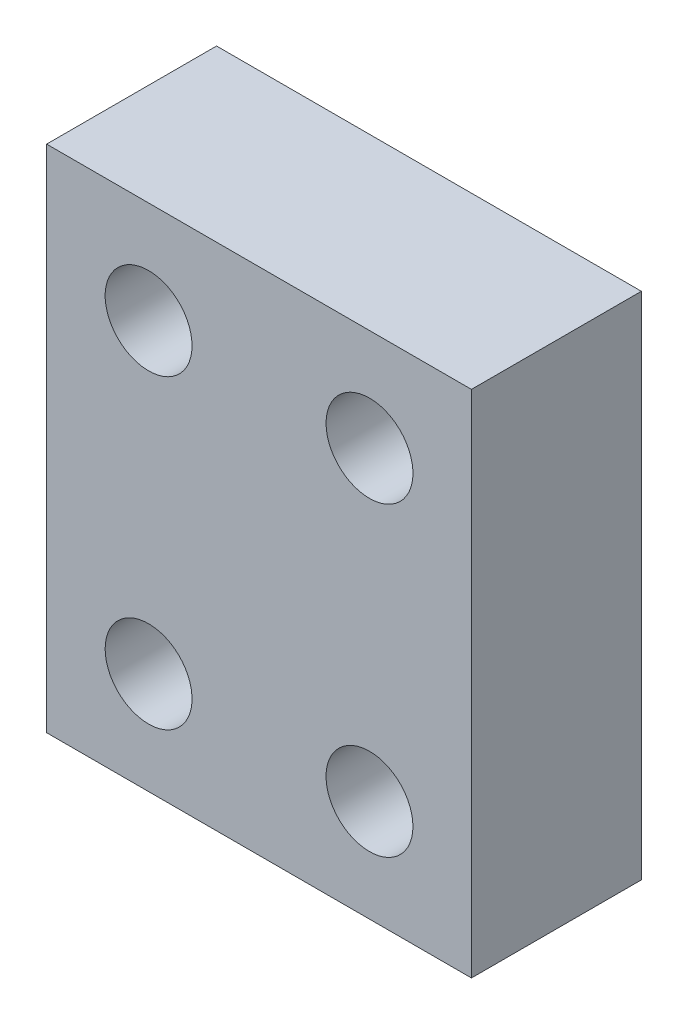
from build123d import *

# Parameters (mm, degrees)
SKETCH1_W           = 25
SKETCH1_H           = 30
SKETCH1_R           = 2.55684
BOSS_EXTRUDE1_DEPTH = 10


with BuildPart() as part:
    # Sketch1 → Boss-Extrude1 (new body)
    with BuildSketch(Plane.XY):
        with Locations((-12.5, 15)):
            Rectangle(SKETCH1_W, SKETCH1_H)
        with Locations((-19, 24)):
            Circle(SKETCH1_R, mode=Mode.SUBTRACT)
        with Locations((-6, 24)):
            Circle(SKETCH1_R, mode=Mode.SUBTRACT)
        with Locations((-6, 6)):
            Circle(SKETCH1_R, mode=Mode.SUBTRACT)
        with Locations((-19, 6)):
            Circle(SKETCH1_R, mode=Mode.SUBTRACT)
    extrude(amount=BOSS_EXTRUDE1_DEPTH)


solid = part.part
